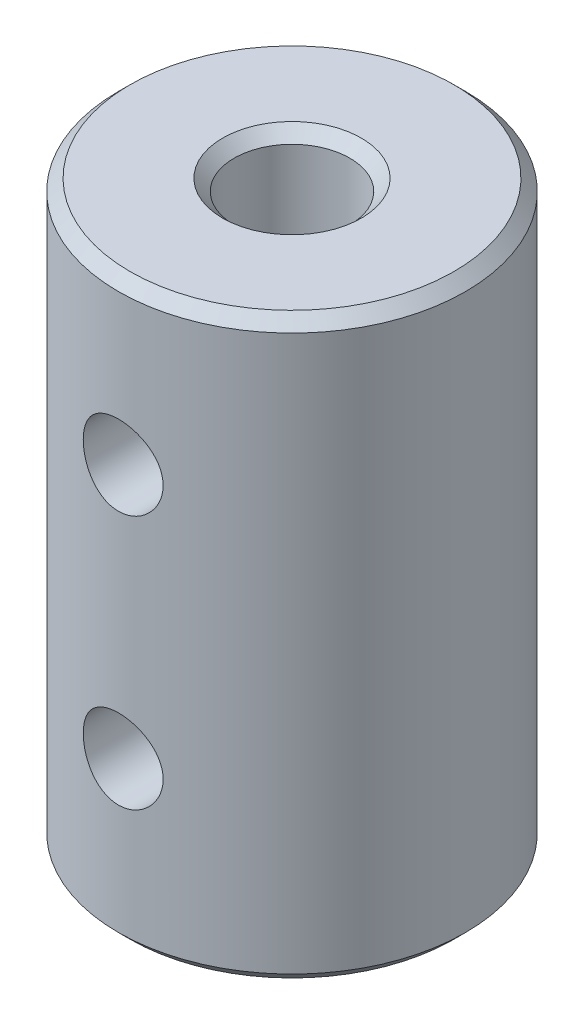
from build123d import *

# Parameters (mm, degrees)
SKETCH1_R                 = 7.5
SKETCH1_R_2               = 2.5
BOSS_EXTRUDE1_DEPTH       = 25
CHAMFER1_SIZE             = 0.5
F_8_32_TAPPED_HOLE1_D     = 3.4544
F_8_32_TAPPED_HOLE1_DEPTH = 18
F_8_32_TAPPED_HOLE1_TIP   = 1.037806461


with BuildPart() as part:
    # Sketch1 → Boss-Extrude1 (new body)
    with BuildSketch(Plane(origin=(0, 0, 0), x_dir=(1, 0, 0), z_dir=(0, 1, 0))):
        Circle(SKETCH1_R)
        Circle(SKETCH1_R_2, mode=Mode.SUBTRACT)
    extrude(amount=BOSS_EXTRUDE1_DEPTH)

    # Chamfer1
    chamfer1_edges = [part.edges().sort_by_distance(p)[0] for p in [
        (-7.5, 0, 0),
        (-7.5, 25, 0),
        (-2.5, 0, 0),
        (-2.5, 25, 0),
    ]]
    chamfer(chamfer1_edges, length=CHAMFER1_SIZE)

    # #8-32 Tapped Hole1
    with Locations(Plane.XY.offset(19.05)):
        with Locations((0, 18), (0, 7)):
            Hole(F_8_32_TAPPED_HOLE1_D / 2, depth=F_8_32_TAPPED_HOLE1_DEPTH)
            with Locations((0, 0, -(F_8_32_TAPPED_HOLE1_DEPTH + F_8_32_TAPPED_HOLE1_TIP / 2))):  # 118° drill point
                Cone(0, F_8_32_TAPPED_HOLE1_D / 2, F_8_32_TAPPED_HOLE1_TIP, mode=Mode.SUBTRACT)


solid = part.part
